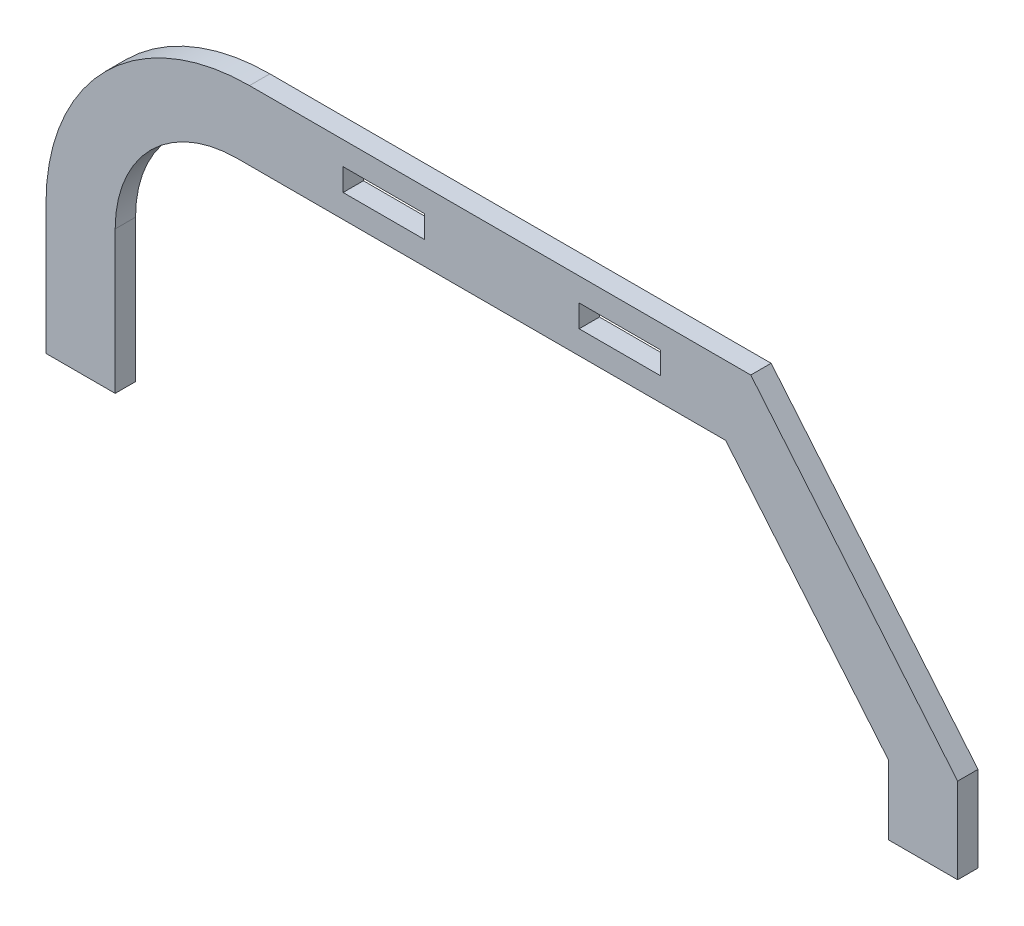
from build123d import *

# Parameters (mm, degrees)
SKETCH1_W           = 20
SKETCH1_H           = 5.5
BOSS_EXTRUDE1_DEPTH = 5


with BuildPart() as part:
    # Sketch1 → Boss-Extrude1 (new body)
    with BuildSketch(Plane.XY):
        with BuildLine():
            Line((-112, 0), (-95, 0))
            Line((-95, 0), (-95, 17))
            Line((-95, 17), (-95, 35))
            ThreePointArc((-95, 35), (-86.213203436, 56.213203436), (-65, 65))
            Line((-65, 65), (-55, 65))
            Line((-55, 65), (55, 65))
            Line((55, 65), (95, 17))
            Line((95, 17), (95, 0))
            Line((95, 0), (112, 0))
            Line((112, 0), (112, 21))
            Line((112, 21), (61.166666667, 82))
            Line((61.166666667, 82), (-61.166666667, 82))
            Line((-61.166666667, 82), (-62, 82))
            ThreePointArc((-62, 82), (-97.355339059, 67.355339059), (-112, 32))
            Line((-112, 32), (-112, 21))
            Line((-112, 21), (-112, 0))
        make_face()
        with Locations((29, 73.5)):
            Rectangle(SKETCH1_W, SKETCH1_H, mode=Mode.SUBTRACT)
        with Locations((-29, 73.5)):
            Rectangle(SKETCH1_W, SKETCH1_H, mode=Mode.SUBTRACT)
    extrude(amount=BOSS_EXTRUDE1_DEPTH)


solid = part.part
